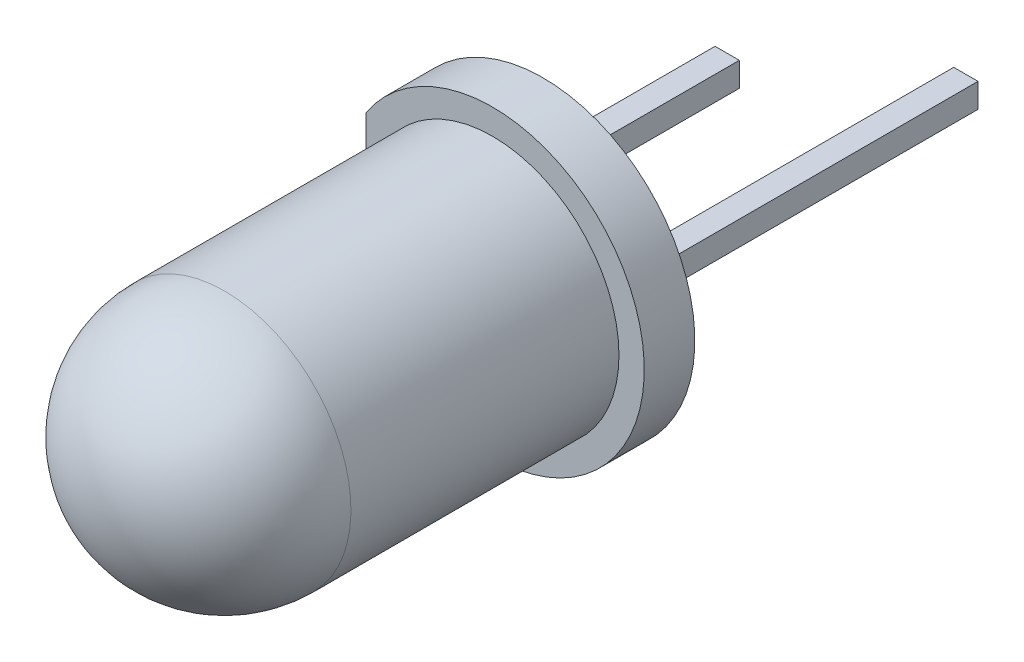
from build123d import *

# Parameters (mm, degrees)
SKETCH1_R             = 3
BOSS_EXTRUDE1_DEPTH   = 1
CUT_EXTRUDE1_DEPTH    = 1
SKETCH4_W             = 0.48
SKETCH4_H             = 0.48
BOSS_EXTRUDE2_DEPTH   = 5
BOSS_EXTRUDE2_2_DEPTH = 5
SKETCH5_W             = 0.48
SKETCH5_H             = 0.48
BOSS_EXTRUDE3_DEPTH   = 2
CUT_EXTRUDE2_DEPTH    = 0.24
BOSS_EXTRUDE4_DEPTH   = 0.24
BOSS_EXTRUDE4_2_DEPTH = 0.24
SKETCH10_R            = 0.2
CUT_EXTRUDE3_DEPTH    = 0.1


with BuildPart() as part:
    # Sketch1 → Boss-Extrude1 (new body)
    with BuildSketch(Plane.XY):
        Circle(SKETCH1_R)
    extrude(amount=BOSS_EXTRUDE1_DEPTH)

    # Sketch2 → Revolve1 (revolve)
    with BuildSketch(Plane(origin=(0, 0, 0), x_dir=(0, 0, -1), z_dir=(1, 0, 0))):
        with BuildLine():
            Line((-1, 0), (-8.8, 0))
            ThreePointArc((-8.8, 0), (-8.067766953, 1.767766953), (-6.3, 2.5))
            Line((-6.3, 2.5), (-1, 2.5))
            Line((-1, 2.5), (-1, 0))
        make_face()
    revolve(axis=Axis((0, 0, 1), (0, 0, 1)))

    # Sketch3 → Cut-Extrude1 (cut)
    with BuildSketch(Plane(origin=(0, 0, 0), x_dir=(-1, 0, 0), z_dir=(0, 0, -1))):
        with BuildLine():
            Line((2.5, 1.658312395), (2.5, -1.658312395))
            ThreePointArc((2.5, -1.658312395), (3, 0), (2.5, 1.658312395))
        make_face()
    extrude(amount=-CUT_EXTRUDE1_DEPTH, mode=Mode.SUBTRACT)

    # Sketch6 → Cut-Extrude2 (cut, symmetric)
    with BuildSketch(Plane(origin=(0, 0, 0), x_dir=(1, 0, 0), z_dir=(0, 1, 0))):
        Polygon((-1.6, 0), (-1.6, -3.5), (-1.3, -4), (1.2, -4), (0.02, -2), (-1.12, -2), (-1.12, 0), align=None)
        Polygon((1.6, 0), (1.6, -4), (1.4, -4), (0.22, -2), (1.12, -2), (1.12, 0), align=None)
    extrude(amount=CUT_EXTRUDE2_DEPTH, both=True, mode=Mode.SUBTRACT)


with BuildPart() as body_2:
    # Sketch4 → Boss-Extrude2 (new body)
    with BuildSketch(Plane(origin=(0, 0, 0), x_dir=(-1, 0, 0), z_dir=(0, 0, -1))):
        with Locations((-1.36, 0)):
            Rectangle(SKETCH4_W, SKETCH4_H)
    extrude(amount=BOSS_EXTRUDE2_DEPTH)


with BuildPart() as body_3:
    # Sketch4 → Boss-Extrude2 2 (new body)
    with BuildSketch(Plane(origin=(0, 0, 0), x_dir=(-1, 0, 0), z_dir=(0, 0, -1))):
        with Locations((1.36, 0)):
            Rectangle(SKETCH4_W, SKETCH4_H)
    extrude(amount=BOSS_EXTRUDE2_2_DEPTH)


with BuildPart() as body_4:
    # Sketch5 → Boss-Extrude3 (new body)
    with BuildSketch(Plane(origin=(0, 0, -5), x_dir=(-1, 0, 0), z_dir=(0, 0, -1))):
        with Locations((-1.36, 0)):
            Rectangle(SKETCH5_W, SKETCH5_H)
    extrude(amount=BOSS_EXTRUDE3_DEPTH)


with BuildPart() as body_5:
    # Sketch7 → Boss-Extrude4 (new body, symmetric)
    with BuildSketch(Plane(origin=(0, 0, 0), x_dir=(1, 0, 0), z_dir=(0, 1, 0))):
        Polygon((-1.3, -4), (1.2, -4), (0.02, -2), (-1.12, -2), (-1.12, 0), (-1.6, 0), (-1.6, -3.5), align=None)
    extrude(amount=BOSS_EXTRUDE4_DEPTH, both=True)

    # Combine2: union body 3
    add(body_3.part)

    # Sketch8 → Cut-Revolve1 (revolve, cut)
    with BuildSketch(Plane(origin=(0, 0, 0), x_dir=(1, 0, 0), z_dir=(0, 1, 0))):
        with BuildLine():
            Line((-0.05, -4), (-0.05, -3.7))
            ThreePointArc((-0.05, -3.7), (-0.341547595, -3.780754009), (-0.55, -4))
            Line((-0.55, -4), (-0.05, -4))
        make_face()
    revolve(axis=Axis((-0.05, 0, 4), (0, 0, -1)), mode=Mode.SUBTRACT)


with BuildPart() as body_6:
    # Sketch7 → Boss-Extrude4 2 (new body, symmetric)
    with BuildSketch(Plane(origin=(0, 0, 0), x_dir=(1, 0, 0), z_dir=(0, 1, 0))):
        Polygon((0.22, -2), (1.4, -4), (1.6, -4), (1.6, 0), (1.12, 0), (1.12, -2), align=None)
    extrude(amount=BOSS_EXTRUDE4_2_DEPTH, both=True)

    # Combine1: union body 4, body 2
    add(body_4.part)
    add(body_2.part)


with BuildPart() as body_4_2:
    # Sketch9 → Revolve2 (revolve)
    with BuildSketch(Plane(origin=(0, 0, 0), x_dir=(1, 0, 0), z_dir=(0, 1, 0))):
        with BuildLine():
            Line((-0.55, -4), (-0.05, -4))
            Line((-0.05, -4), (-0.05, -3.7))
            ThreePointArc((-0.05, -3.7), (-0.341547595, -3.780754009), (-0.55, -4))
        make_face()
    revolve(axis=Axis((-0.05, 0, 4), (0, 0, -1)))

    # Combine3: union body 5
    add(body_5.part)

    # Sketch10 → Cut-Extrude3 (cut)
    with BuildSketch(Plane.XY.offset(4)):
        with Locations((-0.05, 0)):
            Circle(SKETCH10_R)
    extrude(amount=-CUT_EXTRUDE3_DEPTH, mode=Mode.SUBTRACT)


solid = Compound([part.part, body_6.part, body_4_2.part])
